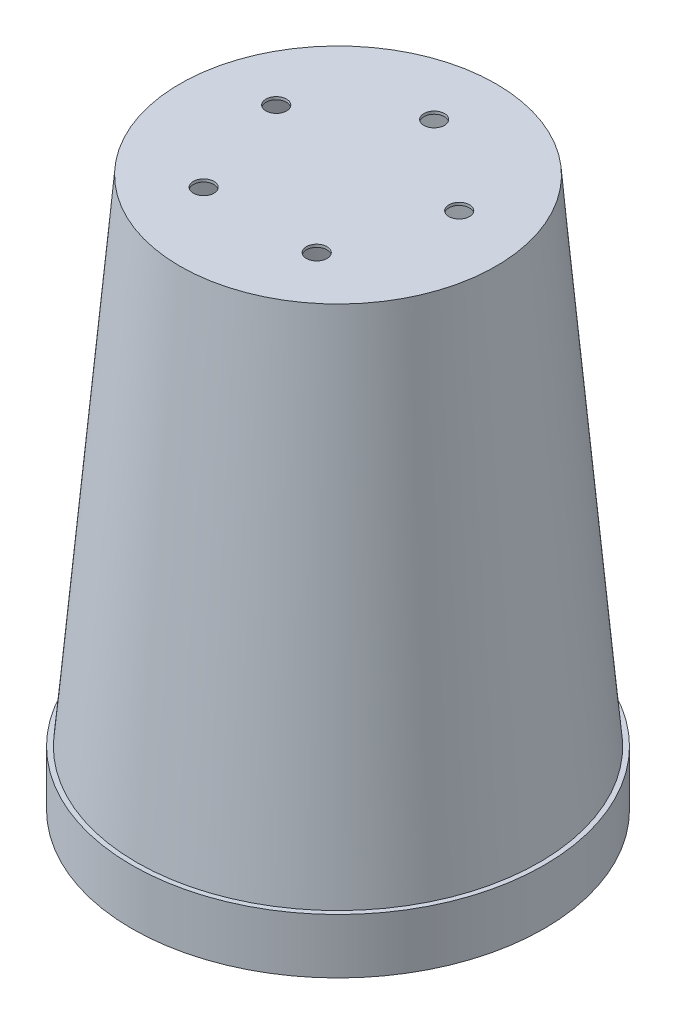
from build123d import *

# Parameters (mm, degrees)
SKETCH1_R           = 75
BOSS_EXTRUDE1_DEPTH = 200
BOSS_EXTRUDE1_TAPER = 5
SKETCH2_R           = 75
BOSS_EXTRUDE2_DEPTH = 20
SHELL2_T            = -1
CUT_EXTRUDE1_REACH  = 228.385
SKETCH3_R           = 3.75
CIRPATTERN1_COUNT   = 5


with BuildPart() as part:
    # Sketch1 → Boss-Extrude1 (new body)
    with BuildSketch(Plane(origin=(0, 0, 0), x_dir=(1, 0, 0), z_dir=(0, 1, 0))):
        Circle(SKETCH1_R)
    extrude(amount=BOSS_EXTRUDE1_DEPTH, taper=BOSS_EXTRUDE1_TAPER)

    # Sketch2 → Boss-Extrude2 (add)
    with BuildSketch(Plane(origin=(0, 0, 0), x_dir=(1, 0, 0), z_dir=(0, 1, 0))):
        with Locations(Location((0, 0, 0), (0, 0, 270))):
            Circle(SKETCH2_R)
    extrude(amount=BOSS_EXTRUDE2_DEPTH)

    # Shell2
    shell2_openings = [part.faces().sort_by_distance(p)[0] for p in [
        (0, 0, 0),
    ]]
    offset(amount=SHELL2_T, openings=shell2_openings, kind=Kind.INTERSECTION)

    # Sketch3 → Cut-Extrude1 (cut, up to next)
    with BuildSketch(Plane(origin=(0, 200, 0), x_dir=(1, 0, 0), z_dir=(0, 1, 0)), mode=Mode.PRIVATE) as cut_extrude1_sk1:
        with Locations(Location((0, 35, 0), (0, 0, 270))):
            Circle(SKETCH3_R)
    cut_extrude1_tool1 = extrude(cut_extrude1_sk1.sketch, amount=-CUT_EXTRUDE1_REACH, mode=Mode.PRIVATE) & part.part
    cut_extrude1 = cut_extrude1_tool1.solids().sort_by_distance((0, 200, -35))[0]
    add(cut_extrude1, mode=Mode.SUBTRACT)

    # CirPattern1: Cut-Extrude1 ×5 about axis
    cirpattern1_axis = Axis((0, 0, 0), (0, 1, 0))
    for i in range(1, CIRPATTERN1_COUNT):
        add(cut_extrude1.rotate(cirpattern1_axis, i * 360 / CIRPATTERN1_COUNT), mode=Mode.SUBTRACT)


solid = part.part
